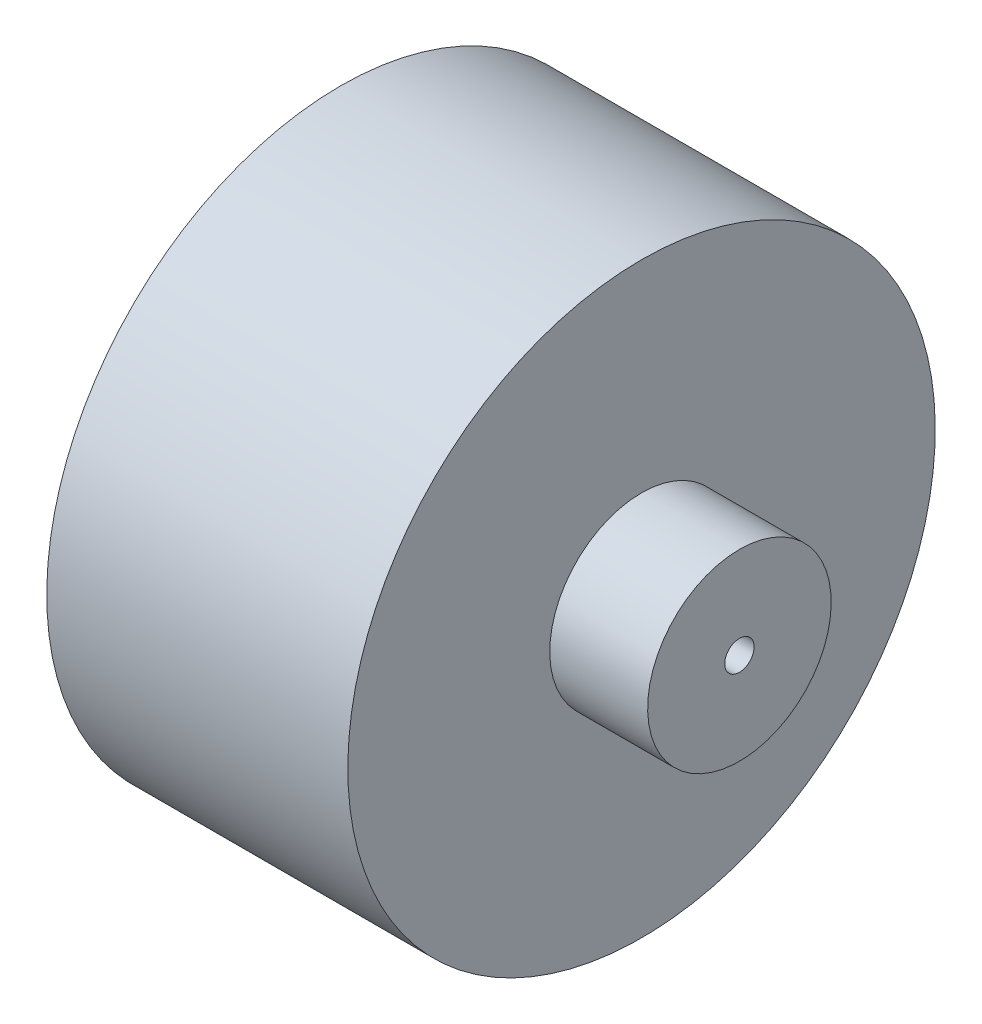
from build123d import *


with BuildPart() as part:
    # Sketch1 → Revolve1 (revolve)
    with BuildSketch(Plane.XY):
        Polygon((-25, 0), (-163, 0), (-163, 120), (-40, 120), (-40, 37.5), (0, 37.5), (0, 6), (-25, 6), align=None)
    revolve(axis=Axis((0, 0, 0), (-1, 0, 0)))


solid = part.part
